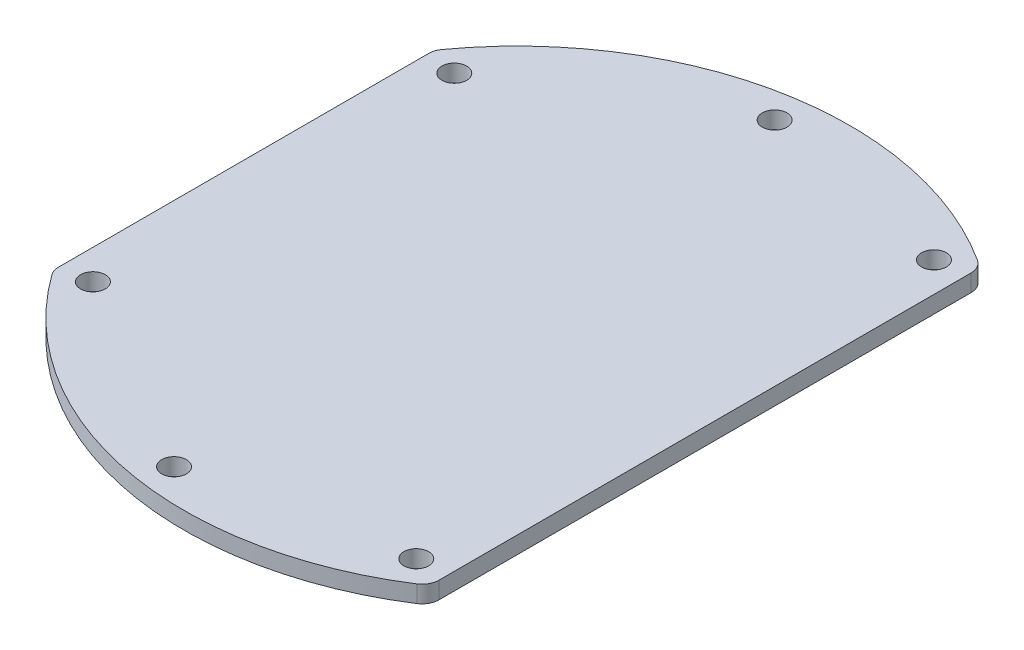
from build123d import *

# Parameters (mm, degrees)
BOSS_EXTRUDE1_DEPTH        = 2
FILLET1_R                  = 2
F_2_9_2_9_DIAMETER_HOLE1_D = 2.9


with BuildPart() as part:
    # Sketch1 → Boss-Extrude1 (new body)
    with BuildSketch(Plane(origin=(0, 0, 0), x_dir=(1, 0, 0), z_dir=(0, 1, 0))):
        with BuildLine():
            Line((-32, 22.29349681), (-32, -22.29349681))
            ThreePointArc((-32, -22.29349681), (-7.038963606, -38.359522825), (22, -32.202484376))
            Line((22, -32.202484376), (22, 32.202484376))
            ThreePointArc((22, 32.202484376), (-7.038963606, 38.359522825), (-32, 22.29349681))
        make_face()
    extrude(amount=BOSS_EXTRUDE1_DEPTH)

    # Fillet1
    fillet1_edges = [part.edges().sort_by_distance(p)[0] for p in [
        (22, 1, -32.202484376),
        (22, 1, 32.202484376),
        (-32, 1, 22.29349681),
        (-32, 1, -22.29349681),
    ]]
    fillet(fillet1_edges, radius=FILLET1_R)

    # Ø2.9 (2.9) Diameter Hole1 (through all)
    with Locations(Plane(origin=(0, 2, 0), x_dir=(1, 0, 0), z_dir=(0, 1, 0))):
        with Locations((-28.5, 21.15), (-28.5, -21.15), (18.5, -30.3), (18.5, 30.3), (-5, 35.15), (-5, -35.15)):
            Hole(F_2_9_2_9_DIAMETER_HOLE1_D / 2)


solid = part.part
